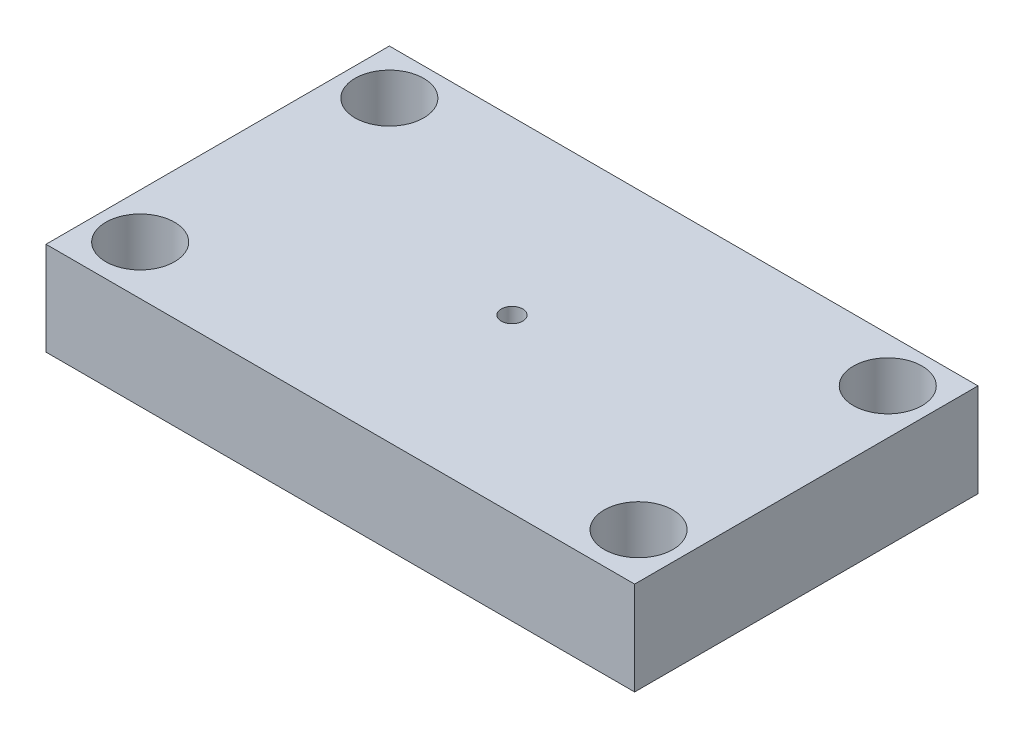
from build123d import *

# Parameters (mm, degrees)
SKETCH1_W           = 60
SKETCH1_H           = 35
SKETCH1_R           = 3.5
SKETCH1_R_2         = 1.0875
BOSS_EXTRUDE1_DEPTH = 9.525


with BuildPart() as part:
    # Sketch1 → Boss-Extrude1 (new body)
    with BuildSketch(Plane(origin=(0, 0, 0), x_dir=(1, 0, 0), z_dir=(0, 1, 0))):
        with Locations((30, 17.5)):
            Rectangle(SKETCH1_W, SKETCH1_H)
        with Locations((4.6, 30.4)):
            Circle(SKETCH1_R, mode=Mode.SUBTRACT)
        with Locations((55.4, 30.4)):
            Circle(SKETCH1_R, mode=Mode.SUBTRACT)
        with Locations((4.6, 5)):
            Circle(SKETCH1_R, mode=Mode.SUBTRACT)
        with Locations((55.4, 5)):
            Circle(SKETCH1_R, mode=Mode.SUBTRACT)
        with Locations((30, 17.5)):
            Circle(SKETCH1_R_2, mode=Mode.SUBTRACT)
    extrude(amount=BOSS_EXTRUDE1_DEPTH)


solid = part.part
